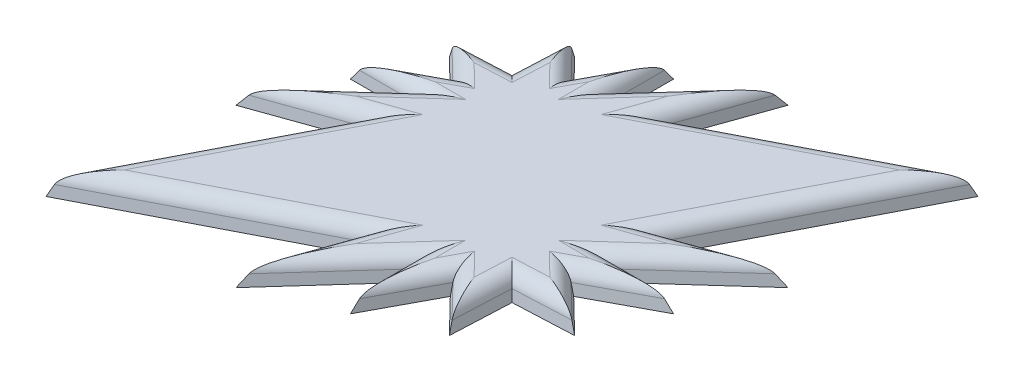
from build123d import *

# Parameters (mm, degrees)
BOSS_EXTRUDE1_DEPTH = 1.5
BOSS_EXTRUDE1_DRAFT = 10
FILLET1_R           = 1


with BuildPart() as part:
    # Sketch2 → Boss-Extrude1 (with draft: the straight prism first)
    with BuildSketch(Plane(origin=(0, 0, 0), x_dir=(1, 0, 0), z_dir=(0, 1, 0))):
        Polygon((15.165421668, 15.165421668), (1.758667474, 8.275044622), (3.841126106, 14.123164889), (-1.358054626, 8.350147449), (-1.358054626, 11.87639847), (-3.626484108, 7.643159543), (-5.804072026, 9.87907884), (-5.982026195, 5.982026195), (-9.87907884, 5.804072026), (-7.643159543, 3.626484108), (-11.87639847, 1.358054626), (-8.350147449, 1.358054626), (-14.123164889, -3.841126106), (-8.275044622, -1.758667474), (-15.165421668, -15.165421668), (-1.758667474, -8.275044622), (-3.841126106, -14.123164889), (1.358054626, -8.350147449), (1.358054626, -11.87639847), (3.626484108, -7.643159543), (5.804072026, -9.87907884), (5.982026195, -5.982026195), (9.87907884, -5.804072026), (7.643159543, -3.626484108), (11.87639847, -1.358054626), (8.350147449, -1.358054626), (14.123164889, 3.841126106), (8.275044622, 1.758667474), align=None)
    extrude(amount=BOSS_EXTRUDE1_DEPTH)
    # Boss-Extrude1: the draft: its side faces are tilted about the plane it starts from
    boss_extrude1_sides = [part.faces().sort_by_distance(p)[0] for p in [
        (8.462044571, 0.75, -11.720233145),
        (2.79989679, 0.75, -11.199104756),
        (1.24153574, 0.75, -11.236656169),
        (-1.358054626, 0.75, -10.11327296),
        (-2.492269367, 0.75, -9.759779007),
        (-4.715278067, 0.75, -8.761119192),
        (-5.893049111, 0.75, -7.930552518),
        (-7.930552518, 0.75, -5.893049111),
        (-8.761119192, 0.75, -4.715278067),
        (-9.759779007, 0.75, -2.492269367),
        (-10.11327296, 0.75, -1.358054626),
        (-11.236656169, 0.75, 1.24153574),
        (-11.199104756, 0.75, 2.79989679),
        (-11.720233145, 0.75, 8.462044571),
        (-8.462044571, 0.75, 11.720233145),
        (-2.79989679, 0.75, 11.199104756),
        (-1.24153574, 0.75, 11.236656169),
        (1.358054626, 0.75, 10.11327296),
        (2.492269367, 0.75, 9.759779007),
        (4.715278067, 0.75, 8.761119192),
        (5.893049111, 0.75, 7.930552518),
        (7.930552518, 0.75, 5.893049111),
        (8.761119192, 0.75, 4.715278067),
        (9.759779007, 0.75, 2.492269367),
        (10.11327296, 0.75, 1.358054626),
        (11.236656169, 0.75, -1.24153574),
        (11.199104756, 0.75, -2.79989679),
        (11.720233145, 0.75, -8.462044571),
    ]]
    draft(boss_extrude1_sides, Plane(origin=(0, 0, 0), x_dir=(1, 0, 0), z_dir=(0, 1, 0)), BOSS_EXTRUDE1_DRAFT)

    # Fillet1
    fillet1_edges = [part.edges().sort_by_distance(p)[0] for p in [
        (7.493053935, 1.5, 5.648260868),
        (8.228576561, 1.5, 4.565827715),
        (9.01135359, 1.5, 2.593250574),
        (9.24203866, 1.5, 1.622545097),
        (10.307546597, 1.5, -0.760721217),
        (10.344144368, 1.5, -2.214694848),
        (11.144016172, 1.5, -7.919500612),
        (7.919500612, 1.5, -11.144016172),
        (2.214694848, 1.5, -10.344144368),
        (0.760721217, 1.5, -10.307546597),
        (4.565827715, 1.5, 8.228576561),
        (-1.622545097, 1.5, -9.24203866),
        (-2.593250574, 1.5, -9.01135359),
        (-4.565827715, 1.5, -8.228576561),
        (-5.648260868, 1.5, -7.493053935),
        (-7.493053935, 1.5, -5.648260868),
        (-8.228576561, 1.5, -4.565827715),
        (-9.01135359, 1.5, -2.593250574),
        (-9.24203866, 1.5, -1.622545097),
        (-10.307546597, 1.5, 0.760721217),
        (-10.344144368, 1.5, 2.214694848),
        (5.648260868, 1.5, 7.493053935),
        (-11.144016172, 1.5, 7.919500612),
        (-7.919500612, 1.5, 11.144016172),
        (-2.214694848, 1.5, 10.344144368),
        (-0.760721217, 1.5, 10.307546597),
        (1.622545097, 1.5, 9.24203866),
        (2.593250574, 1.5, 9.01135359),
    ]]
    fillet(fillet1_edges, radius=FILLET1_R)


solid = part.part
